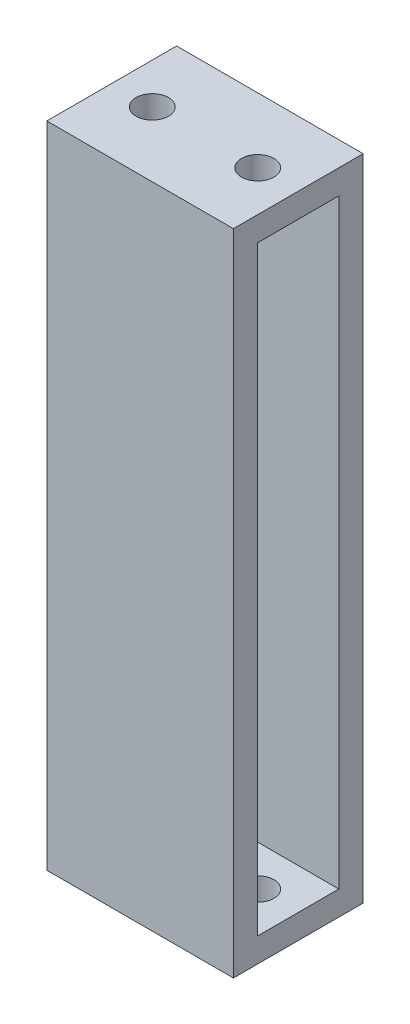
from build123d import *

# Parameters (mm, degrees)
EXTRUDE_1_DEPTH          = 80
SKETCH_2_W               = 10
SKETCH_2_H               = 3
EXTRUDE_2_DEPTH          = 11.5
SKETCH_3_R               = 2
CUT_EXTRUDE_2_DEPTH      = 81
CUT_EXTRUDE_2_DEPTH_BACK = 1


with BuildPart() as part:
    # 草图1 → 凸台-拉伸1 (new body)
    with BuildSketch(Plane(origin=(0, 0, 0), x_dir=(1, 0, 0), z_dir=(0, 1, 0))):
        Polygon((11.5, 5), (11.5, 8), (-11.5, 8), (-11.5, 5), (-1.5, 5), (-1.5, -5), (-11.5, -5), (-11.5, -8), (11.5, -8), (11.5, -5), (1.5, -5), (1.5, 5), align=None)
    extrude(amount=EXTRUDE_1_DEPTH)

    # 草图2 → 凸台-拉伸2 (add, symmetric)
    with BuildSketch(Plane(origin=(0, 0, 0), x_dir=(0, 0, -1), z_dir=(1, 0, 0))):
        with Locations((0, 1.5)):
            Rectangle(SKETCH_2_W, SKETCH_2_H)
        with Locations((0, 78.5)):
            Rectangle(SKETCH_2_W, SKETCH_2_H)
    extrude(amount=EXTRUDE_2_DEPTH, both=True)

    # 草图3 → 切除-拉伸2 (cut, two sides)
    with BuildSketch(Plane(origin=(0, 0, 0), x_dir=(1, 0, 0), z_dir=(0, 1, 0))) as cut_extrude_2_sk:
        with Locations((6.5, 0)):
            Circle(SKETCH_3_R)
        with Locations((-6.5, 0)):
            Circle(SKETCH_3_R)
    extrude(amount=CUT_EXTRUDE_2_DEPTH, mode=Mode.SUBTRACT)
    extrude(cut_extrude_2_sk.sketch, amount=-CUT_EXTRUDE_2_DEPTH_BACK, mode=Mode.SUBTRACT)


solid = part.part
